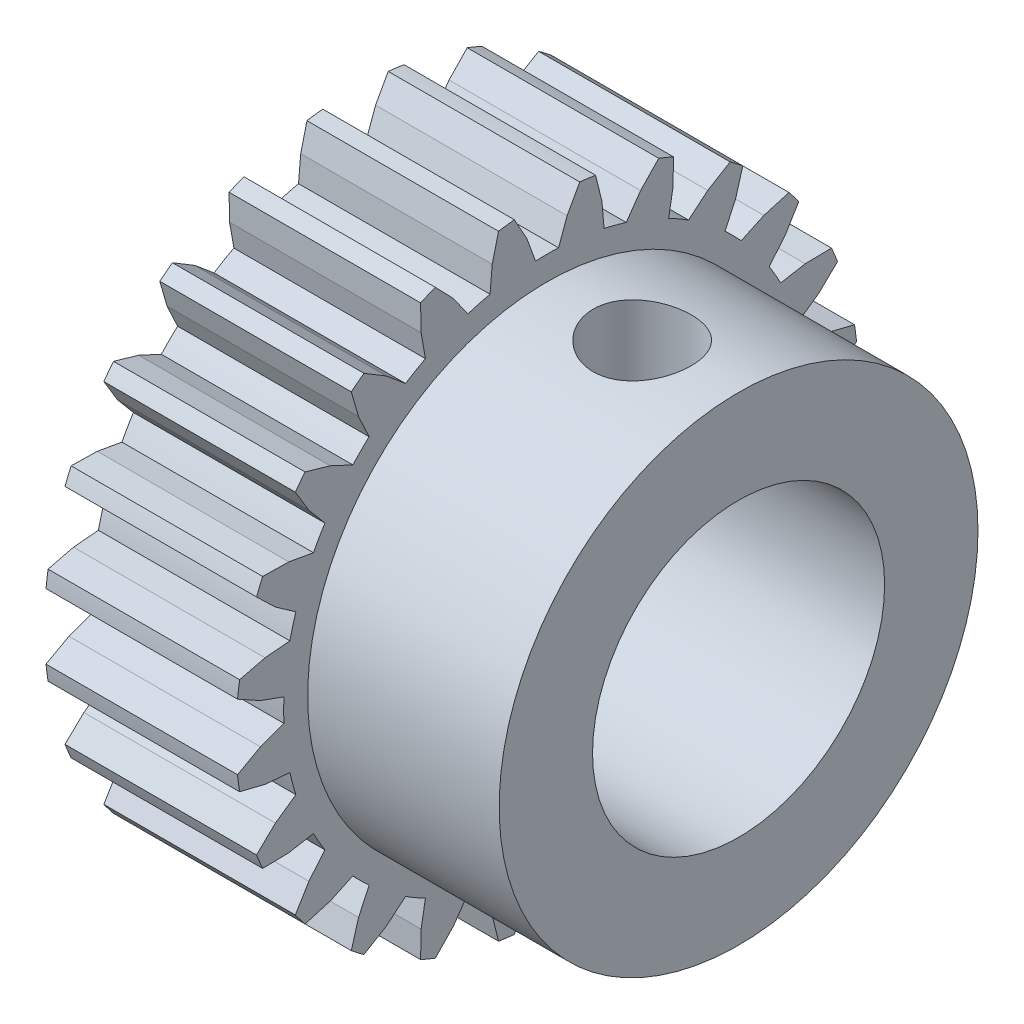
from build123d import *

# Parameters (mm, degrees)
BOSS_EXTRUDE1_DEPTH            = 4
SKETCH2_W                      = 4
SKETCH2_H                      = 5
F_6_1_6_1_DIAMETER_HOLE1_D     = 6.1
F_6_1_6_1_DIAMETER_HOLE1_DEPTH = 8
SKETCH5_W                      = 1.025
SKETCH5_H                      = 10


with BuildPart() as part:
    # Sketch1 → Boss-Extrude1 (new body)
    with BuildSketch(Plane(origin=(2, 0, 0), x_dir=(0, 0, -1), z_dir=(1, 0, 0))):
        with BuildLine():
            Line((-5.494765219, -0.239906631), (-5.985388493, -0.418478899))
            Line((-5.985388493, -0.418478899), (-6.464027144, -0.682900491))
            ThreePointArc((-6.464027144, -0.682900491), (-6.444391599, -0.84842025), (-6.420518413, -1.013382112))
            Line((-6.420518413, -1.013382112), (-5.889751635, -1.144912958))
            Line((-5.889751635, -1.144912958), (-5.369628039, -1.190417877))
            ThreePointArc((-5.369628039, -1.190417877), (-5.312592045, -1.423504748), (-5.245443229, -1.653881897))
            Line((-5.245443229, -1.653881897), (-5.673131017, -1.95335211))
            Line((-5.673131017, -1.95335211), (-6.067023107, -2.332644554))
            ThreePointArc((-6.067023107, -2.332644554), (-6.005216961, -2.487442311), (-5.939461963, -2.640604399))
            Line((-5.939461963, -2.640604399), (-5.392737936, -2.630280889))
            Line((-5.392737936, -2.630280889), (-4.878559582, -2.539617373))
            ThreePointArc((-4.878559582, -2.539617373), (-4.763139721, -2.750000001), (-4.638652952, -2.955147847))
            Line((-4.638652952, -2.955147847), (-4.974259037, -3.355107604))
            Line((-4.974259037, -3.355107604), (-5.256561472, -3.823422746))
            ThreePointArc((-5.256561472, -3.823422746), (-5.156796712, -3.956949288), (-5.053640997, -4.087873858))
            Line((-5.053640997, -4.087873858), (-4.528218058, -3.936399524))
            Line((-4.528218058, -3.936399524), (-4.055025352, -3.715746142))
            ThreePointArc((-4.055025352, -3.715746142), (-3.889087296, -3.889087297), (-3.715746141, -4.055025353))
            Line((-3.715746141, -4.055025353), (-3.936399524, -4.528218058))
            Line((-3.936399524, -4.528218058), (-4.087873859, -5.053640996))
            ThreePointArc((-4.087873859, -5.053640996), (-3.956949289, -5.156796712), (-3.823422746, -5.256561471))
            Line((-3.823422746, -5.256561471), (-3.355107604, -4.974259037))
            Line((-3.355107604, -4.974259037), (-2.955147846, -4.638652952))
            ThreePointArc((-2.955147846, -4.638652952), (-2.75, -4.763139721), (-2.539617374, -4.878559582))
            Line((-2.539617374, -4.878559582), (-2.630280889, -5.392737936))
            Line((-2.630280889, -5.392737936), (-2.640604398, -5.939461963))
            ThreePointArc((-2.640604398, -5.939461963), (-2.48744231, -6.005216961), (-2.332644554, -6.067023107))
            Line((-2.332644554, -6.067023107), (-1.95335211, -5.673131017))
            Line((-1.95335211, -5.673131017), (-1.653881897, -5.245443229))
            ThreePointArc((-1.653881897, -5.245443229), (-1.423504748, -5.312592045), (-1.190417877, -5.369628039))
            Line((-1.190417877, -5.369628039), (-1.144912958, -5.889751635))
            Line((-1.144912958, -5.889751635), (-1.013382112, -6.420518413))
            ThreePointArc((-1.013382112, -6.420518413), (-0.848420249, -6.444391599), (-0.682900491, -6.464027144))
            Line((-0.682900491, -6.464027144), (-0.418478899, -5.985388493))
            Line((-0.418478899, -5.985388493), (-0.239906631, -5.494765219))
            ThreePointArc((-0.239906631, -5.494765219), (0, -5.5), (0.239906631, -5.494765219))
            Line((0.239906631, -5.494765219), (0.418478899, -5.985388493))
            Line((0.418478899, -5.985388493), (0.682900491, -6.464027144))
            ThreePointArc((0.682900491, -6.464027144), (0.84842025, -6.444391599), (1.013382113, -6.420518413))
            Line((1.013382113, -6.420518413), (1.144912958, -5.889751635))
            Line((1.144912958, -5.889751635), (1.190417877, -5.369628039))
            ThreePointArc((1.190417877, -5.369628039), (1.423504749, -5.312592045), (1.653881898, -5.245443229))
            Line((1.653881898, -5.245443229), (1.95335211, -5.673131017))
            Line((1.95335211, -5.673131017), (2.332644554, -6.067023107))
            ThreePointArc((2.332644554, -6.067023107), (2.48744231, -6.005216962), (2.640604397, -5.939461964))
            Line((2.640604397, -5.939461964), (2.630280889, -5.392737936))
            Line((2.630280889, -5.392737936), (2.539617373, -4.878559582))
            ThreePointArc((2.539617373, -4.878559582), (2.750000001, -4.76313972), (2.955147847, -4.638652951))
            Line((2.955147847, -4.638652951), (3.355107604, -4.974259037))
            Line((3.355107604, -4.974259037), (3.823422746, -5.256561472))
            ThreePointArc((3.823422746, -5.256561472), (3.956949288, -5.156796712), (4.087873858, -5.053640996))
            Line((4.087873858, -5.053640996), (3.936399524, -4.528218058))
            Line((3.936399524, -4.528218058), (3.715746142, -4.055025352))
            ThreePointArc((3.715746142, -4.055025352), (3.889087296, -3.889087297), (4.055025352, -3.715746143))
            Line((4.055025352, -3.715746143), (4.528218058, -3.936399524))
            Line((4.528218058, -3.936399524), (5.053640996, -4.087873859))
            ThreePointArc((5.053640996, -4.087873859), (5.156796712, -3.956949289), (5.256561472, -3.823422746))
            Line((5.256561472, -3.823422746), (4.974259037, -3.355107604))
            Line((4.974259037, -3.355107604), (4.638652952, -2.955147846))
            ThreePointArc((4.638652952, -2.955147846), (4.763139721, -2.75), (4.878559582, -2.539617373))
            Line((4.878559582, -2.539617373), (5.392737936, -2.630280889))
            Line((5.392737936, -2.630280889), (5.939461963, -2.640604398))
            ThreePointArc((5.939461963, -2.640604398), (6.005216962, -2.48744231), (6.067023108, -2.332644554))
            Line((6.067023108, -2.332644554), (5.673131017, -1.95335211))
            Line((5.673131017, -1.95335211), (5.245443229, -1.653881897))
            ThreePointArc((5.245443229, -1.653881897), (5.312592045, -1.423504748), (5.369628039, -1.190417877))
            Line((5.369628039, -1.190417877), (5.889751635, -1.144912958))
            Line((5.889751635, -1.144912958), (6.420518413, -1.013382112))
            ThreePointArc((6.420518413, -1.013382112), (6.444391599, -0.848420249), (6.464027144, -0.68290049))
            Line((6.464027144, -0.68290049), (5.985388493, -0.418478899))
            Line((5.985388493, -0.418478899), (5.494765219, -0.239906631))
            ThreePointArc((5.494765219, -0.239906631), (5.5, 0), (5.494765219, 0.239906631))
            Line((5.494765219, 0.239906631), (5.985388493, 0.418478899))
            Line((5.985388493, 0.418478899), (6.464027144, 0.682900491))
            ThreePointArc((6.464027144, 0.682900491), (6.444391599, 0.848420249), (6.420518413, 1.013382112))
            Line((6.420518413, 1.013382112), (5.889751635, 1.144912958))
            Line((5.889751635, 1.144912958), (5.369628039, 1.190417877))
            ThreePointArc((5.369628039, 1.190417877), (5.312592045, 1.423504748), (5.245443229, 1.653881897))
            Line((5.245443229, 1.653881897), (5.673131017, 1.95335211))
            Line((5.673131017, 1.95335211), (6.067023107, 2.332644554))
            ThreePointArc((6.067023107, 2.332644554), (6.005216961, 2.48744231), (5.939461963, 2.640604398))
            Line((5.939461963, 2.640604398), (5.392737936, 2.630280889))
            Line((5.392737936, 2.630280889), (4.878559582, 2.539617374))
            ThreePointArc((4.878559582, 2.539617374), (4.763139721, 2.75), (4.638652952, 2.955147846))
            Line((4.638652952, 2.955147846), (4.974259037, 3.355107604))
            Line((4.974259037, 3.355107604), (5.256561472, 3.823422746))
            ThreePointArc((5.256561472, 3.823422746), (5.156796712, 3.956949289), (5.053640996, 4.087873859))
            Line((5.053640996, 4.087873859), (4.528218058, 3.936399524))
            Line((4.528218058, 3.936399524), (4.055025352, 3.715746143))
            ThreePointArc((4.055025352, 3.715746143), (3.889087296, 3.889087297), (3.715746142, 4.055025352))
            Line((3.715746142, 4.055025352), (3.936399524, 4.528218058))
            Line((3.936399524, 4.528218058), (4.087873858, 5.053640997))
            ThreePointArc((4.087873858, 5.053640997), (3.956949288, 5.156796712), (3.823422746, 5.256561472))
            Line((3.823422746, 5.256561472), (3.355107604, 4.974259037))
            Line((3.355107604, 4.974259037), (2.955147847, 4.638652952))
            ThreePointArc((2.955147847, 4.638652952), (2.750000001, 4.763139721), (2.539617373, 4.878559582))
            Line((2.539617373, 4.878559582), (2.630280889, 5.392737936))
            Line((2.630280889, 5.392737936), (2.640604399, 5.939461963))
            ThreePointArc((2.640604399, 5.939461963), (2.487442311, 6.005216961), (2.332644554, 6.067023107))
            Line((2.332644554, 6.067023107), (1.95335211, 5.673131017))
            Line((1.95335211, 5.673131017), (1.653881898, 5.245443229))
            ThreePointArc((1.653881898, 5.245443229), (1.423504748, 5.312592045), (1.190417877, 5.369628039))
            Line((1.190417877, 5.369628039), (1.144912958, 5.889751635))
            Line((1.144912958, 5.889751635), (1.013382112, 6.420518413))
            ThreePointArc((1.013382112, 6.420518413), (0.84842025, 6.444391599), (0.682900491, 6.464027144))
            Line((0.682900491, 6.464027144), (0.418478899, 5.985388493))
            Line((0.418478899, 5.985388493), (0.239906631, 5.494765219))
            ThreePointArc((0.239906631, 5.494765219), (0, 5.5), (-0.239906631, 5.494765219))
            Line((-0.239906631, 5.494765219), (-0.418478899, 5.985388493))
            Line((-0.418478899, 5.985388493), (-0.682900491, 6.464027144))
            ThreePointArc((-0.682900491, 6.464027144), (-0.84842025, 6.444391599), (-1.013382112, 6.420518413))
            Line((-1.013382112, 6.420518413), (-1.144912958, 5.889751635))
            Line((-1.144912958, 5.889751635), (-1.190417878, 5.369628039))
            ThreePointArc((-1.190417878, 5.369628039), (-1.423504748, 5.312592045), (-1.653881897, 5.245443229))
            Line((-1.653881897, 5.245443229), (-1.95335211, 5.673131017))
            Line((-1.95335211, 5.673131017), (-2.332644555, 6.067023107))
            ThreePointArc((-2.332644555, 6.067023107), (-2.487442311, 6.005216961), (-2.640604398, 5.939461963))
            Line((-2.640604398, 5.939461963), (-2.630280889, 5.392737936))
            Line((-2.630280889, 5.392737936), (-2.539617374, 4.878559582))
            ThreePointArc((-2.539617374, 4.878559582), (-2.750000001, 4.76313972), (-2.955147846, 4.638652952))
            Line((-2.955147846, 4.638652952), (-3.355107604, 4.974259037))
            Line((-3.355107604, 4.974259037), (-3.823422747, 5.256561471))
            ThreePointArc((-3.823422747, 5.256561471), (-3.956949289, 5.156796712), (-4.087873859, 5.053640996))
            Line((-4.087873859, 5.053640996), (-3.936399524, 4.528218058))
            Line((-3.936399524, 4.528218058), (-3.715746141, 4.055025353))
            ThreePointArc((-3.715746141, 4.055025353), (-3.889087296, 3.889087297), (-4.055025352, 3.715746142))
            Line((-4.055025352, 3.715746142), (-4.528218058, 3.936399524))
            Line((-4.528218058, 3.936399524), (-5.053640995, 4.08787386))
            ThreePointArc((-5.053640995, 4.08787386), (-5.156796711, 3.956949289), (-5.256561472, 3.823422746))
            Line((-5.256561472, 3.823422746), (-4.974259037, 3.355107604))
            Line((-4.974259037, 3.355107604), (-4.638652952, 2.955147846))
            ThreePointArc((-4.638652952, 2.955147846), (-4.763139721, 2.75), (-4.878559582, 2.539617373))
            Line((-4.878559582, 2.539617373), (-5.392737936, 2.630280889))
            Line((-5.392737936, 2.630280889), (-5.939461963, 2.640604399))
            ThreePointArc((-5.939461963, 2.640604399), (-6.005216961, 2.487442311), (-6.067023107, 2.332644554))
            Line((-6.067023107, 2.332644554), (-5.673131017, 1.95335211))
            Line((-5.673131017, 1.95335211), (-5.245443229, 1.653881897))
            ThreePointArc((-5.245443229, 1.653881897), (-5.312592045, 1.423504748), (-5.369628039, 1.190417877))
            Line((-5.369628039, 1.190417877), (-5.889751635, 1.144912958))
            Line((-5.889751635, 1.144912958), (-6.420518413, 1.013382112))
            ThreePointArc((-6.420518413, 1.013382112), (-6.444391599, 0.848420249), (-6.464027144, 0.682900491))
            Line((-6.464027144, 0.682900491), (-5.985388493, 0.418478899))
            Line((-5.985388493, 0.418478899), (-5.494765219, 0.23990663))
            ThreePointArc((-5.494765219, 0.23990663), (-5.5, -1e-09), (-5.494765219, -0.239906631))
        make_face()
    extrude(amount=-BOSS_EXTRUDE1_DEPTH)

    # Sketch2 → Revolve1 (revolve)
    with BuildSketch(Plane.XY):
        with Locations((4, 2.5)):
            Rectangle(SKETCH2_W, SKETCH2_H)
    revolve(axis=Axis((2, 0, 0), (1, 0, 0)))

    # Ø6.1 (6.1) Diameter Hole1
    with Locations(Plane(origin=(6, 0, 0), x_dir=(0, 0, -1), z_dir=(1, 0, 0))):
        with Locations((0, 0)):
            Hole(F_6_1_6_1_DIAMETER_HOLE1_D / 2, depth=F_6_1_6_1_DIAMETER_HOLE1_DEPTH)

    # Sketch5 → Ø2.05 (2.05) Diameter Hole1 (revolve, cut)
    with BuildSketch(Plane(origin=(4, 2.87259786, 0.007519122), x_dir=(0, 0.002617525, -0.999996574), z_dir=(1, 0, 0))):
        with Locations((0.5125, 5)):
            Rectangle(SKETCH5_W, SKETCH5_H)
    revolve(axis=Axis((4, -3.477380387, -0.009102162), (0, 0.999996574, 0.002617525)), mode=Mode.SUBTRACT)


solid = part.part
